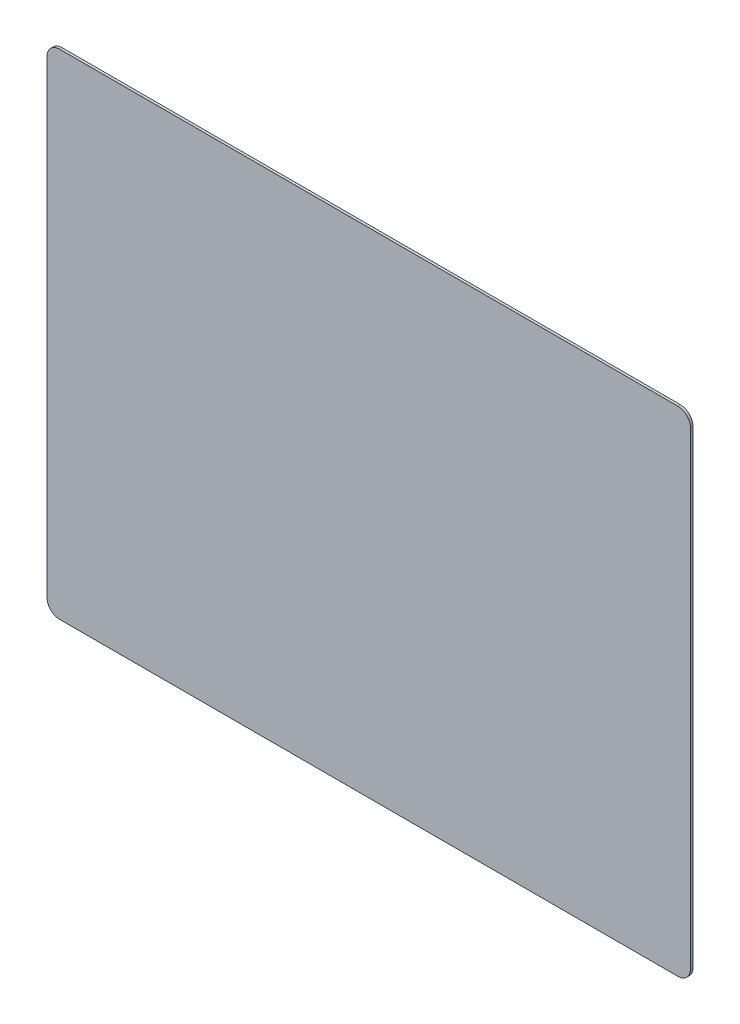
from build123d import *

# Parameters (mm, degrees)
SKETCH1_W           = 1010
SKETCH1_H           = 775
BOSS_EXTRUDE1_DEPTH = 4
FILLET1_R           = 20


with BuildPart() as part:
    # Sketch1 → Boss-Extrude1 (new body)
    with BuildSketch(Plane.XY):
        Rectangle(SKETCH1_W, SKETCH1_H)
    extrude(amount=BOSS_EXTRUDE1_DEPTH)

    # Fillet1
    fillet1_edges = [part.edges().sort_by_distance(p)[0] for p in [
        (505, -387.5, 2),
        (-505, -387.5, 2),
        (-505, 387.5, 2),
        (505, 387.5, 2),
    ]]
    fillet(fillet1_edges, radius=FILLET1_R)


solid = part.part
